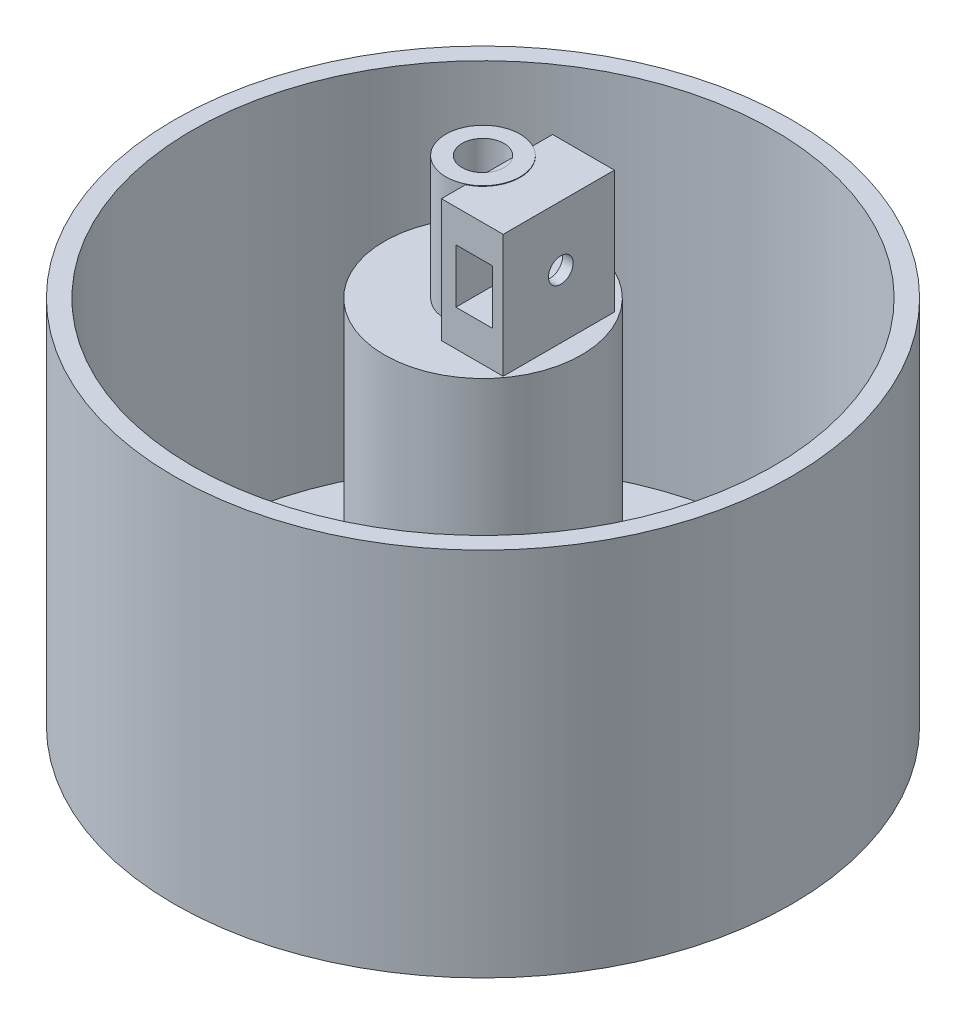
from build123d import *

# Parameters (mm, degrees)
SKETCH1_R               = 6
BOSS_EXTRUDE1_DEPTH     = 20
SKETCH2_R               = 3.4
CUT_EXTRUDE1_DEPTH      = 13.55
SKETCH5_W               = 1.550685087
SKETCH5_H               = 7.184215806
BOSS_EXTRUDE2_DEPTH     = 13.55
SKETCH7_W               = 18.003976239
SKETCH7_H               = 19.909960041
BOSS_EXTRUDE3_DEPTH     = 10
CUT_EXTRUDE2_DEPTH      = 1
CUT_EXTRUDE2_DEPTH_BACK = 13.55
SKETCH6_R               = 2
CUT_EXTRUDE3_DEPTH      = 10
CUT_EXTRUDE3_DEPTH_BACK = 10
SKETCH10_R              = 50
BOSS_EXTRUDE4_DEPTH     = 60
SKETCH12_R              = 47.082764373
SKETCH12_R_2            = 15.95790089
CUT_EXTRUDE5_DEPTH      = 57


with BuildPart() as part:
    # Sketch1 → Boss-Extrude1 (new body)
    with BuildSketch(Plane(origin=(0, 0, 0), x_dir=(1, 0, 0), z_dir=(0, 1, 0))):
        Circle(SKETCH1_R)
    extrude(amount=BOSS_EXTRUDE1_DEPTH)

    # Sketch2 → Cut-Extrude1 (cut)
    with BuildSketch(Plane(origin=(0, 20, 0), x_dir=(1, 0, 0), z_dir=(0, 1, 0))):
        Circle(SKETCH2_R)
    extrude(amount=-CUT_EXTRUDE1_DEPTH, mode=Mode.SUBTRACT)

    # Sketch5 → Boss-Extrude2 (add)
    with BuildSketch(Plane(origin=(0, 18.26, 0), x_dir=(1, 0, 0), z_dir=(0, 1, 0))):
        with Locations((3.375342544, 0.020519704)):
            Rectangle(SKETCH5_W, SKETCH5_H)
    extrude(amount=-BOSS_EXTRUDE2_DEPTH)

    # Sketch7 → Boss-Extrude3 (add)
    with BuildSketch(Plane.ZY.offset(-2.6)):
        with Locations((0.33027221, 9.954980021)):
            Rectangle(SKETCH7_W, SKETCH7_H)
    extrude(amount=-BOSS_EXTRUDE3_DEPTH)

    # Sketch6 → Cut-Extrude2 (cut, two sides: drawn at the far end of the back side and taken through both)
    with BuildSketch(Plane.ZY.offset(-2.6).offset(-CUT_EXTRUDE2_DEPTH_BACK)):
        with Locations((0, 10.236925537)):
            Circle(SKETCH6_R)
    extrude(amount=CUT_EXTRUDE2_DEPTH + CUT_EXTRUDE2_DEPTH_BACK, mode=Mode.SUBTRACT)

    # Sketch9 → Cut-Extrude3 (cut, two sides: drawn at the far end of the back side and taken through both)
    with BuildSketch(Plane.XY.offset(-CUT_EXTRUDE3_DEPTH_BACK)):
        Polygon((10.876516382, 10.236925537), (10.876516382, 5.861925537), (4.943430227, 5.861925537), (4.943430227, 10.236925537), (4.943430227, 14.614332445), (10.876516382, 14.614332445), align=None)
    extrude(amount=CUT_EXTRUDE3_DEPTH + CUT_EXTRUDE3_DEPTH_BACK, mode=Mode.SUBTRACT)

    # Sketch10 → Boss-Extrude4 (add)
    with BuildSketch(Plane.XZ):
        Circle(SKETCH10_R)
    extrude(amount=BOSS_EXTRUDE4_DEPTH)

    # Sketch12 → Cut-Extrude5 (cut)
    with BuildSketch(Plane(origin=(0, 0, 0), x_dir=(1, 0, 0), z_dir=(0, 1, 0))):
        Circle(SKETCH12_R)
        Circle(SKETCH12_R_2, mode=Mode.SUBTRACT)
    extrude(amount=-CUT_EXTRUDE5_DEPTH, mode=Mode.SUBTRACT)


solid = part.part
